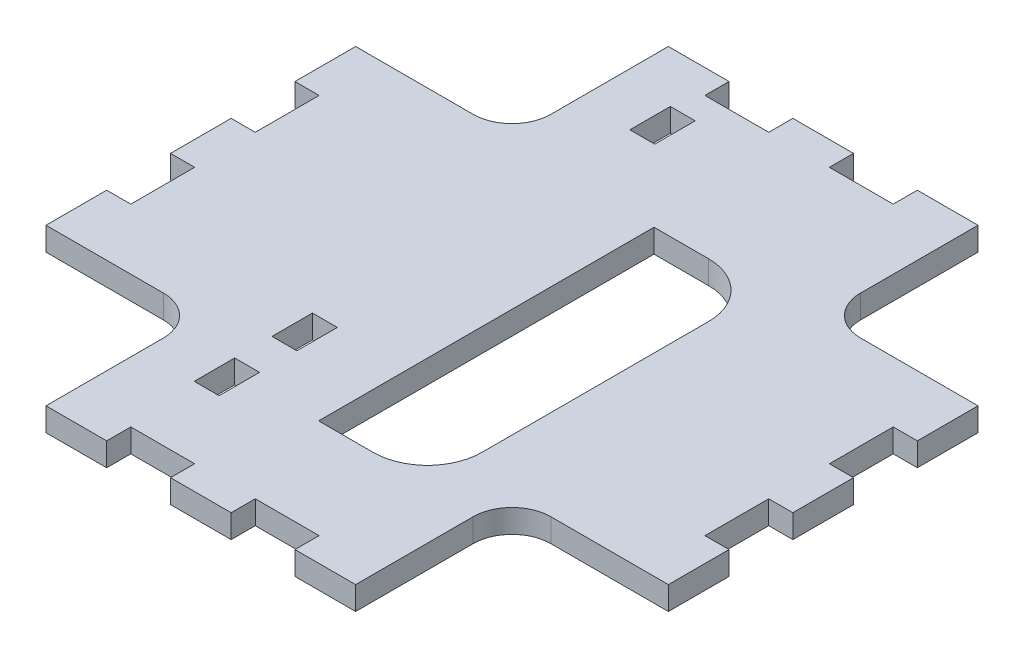
from build123d import *

# Parameters (mm, degrees)
SKETCH1_W           = 80
SKETCH1_H           = 80
SKETCH1_W_2         = 9
SKETCH1_H_2         = 43.113686922
BOSS_EXTRUDE1_DEPTH = 3
SKETCH3_W           = 8.2
SKETCH3_H           = 3.2
SKETCH3_W_2         = 3.2
SKETCH3_H_2         = 8.2
SKETCH3_W_3         = 20.2
SKETCH3_H_3         = 20.2
SKETCH3_H_4         = 5.2
CUT_EXTRUDE1_DEPTH  = 4
FILLET1_R           = 5
SKETCH4_W           = 5
SKETCH4_H           = 43.113686922
CUT_EXTRUDE2_DEPTH  = 4
FILLET2_R           = 7


with BuildPart() as part:
    # Sketch1 → Boss-Extrude1 (new body)
    with BuildSketch(Plane(origin=(0, 0, 0), x_dir=(1, 0, 0), z_dir=(0, 1, 0))):
        with Locations((40, 40)):
            Rectangle(SKETCH1_W, SKETCH1_H)
        with Locations((43.8, 37.4)):
            Rectangle(SKETCH1_W_2, SKETCH1_H_2, mode=Mode.SUBTRACT)
    extrude(amount=-BOSS_EXTRUDE1_DEPTH)

    # Sketch3 → Cut-Extrude1 (cut, through all)
    with BuildSketch(Plane(origin=(0, 0, 0), x_dir=(1, 0, 0), z_dir=(0, 1, 0))):
        with Locations((32, 1.5)):
            Rectangle(SKETCH3_W, SKETCH3_H)
        with Locations((78.5, 32)):
            Rectangle(SKETCH3_W_2, SKETCH3_H_2)
        with Locations((48, 1.5)):
            Rectangle(SKETCH3_W, SKETCH3_H)
        with Locations((1.5, 32)):
            Rectangle(SKETCH3_W_2, SKETCH3_H_2)
        with Locations((10, 10)):
            Rectangle(SKETCH3_W_3, SKETCH3_H_3)
        with Locations((70, 10)):
            Rectangle(SKETCH3_W_3, SKETCH3_H_3)
        with Locations((32, 78.5)):
            Rectangle(SKETCH3_W, SKETCH3_H)
        with Locations((1.5, 48)):
            Rectangle(SKETCH3_W_2, SKETCH3_H_2)
        with Locations((10, 70)):
            Rectangle(SKETCH3_W_3, SKETCH3_H_3)
        with Locations((78.5, 48)):
            Rectangle(SKETCH3_W_2, SKETCH3_H_2)
        with Locations((70, 70)):
            Rectangle(SKETCH3_W_3, SKETCH3_H_3)
        with Locations((48, 78.5)):
            Rectangle(SKETCH3_W, SKETCH3_H)
        with Locations((28.5, 14.85)):
            Rectangle(SKETCH3_W_2, SKETCH3_H_4)
        with Locations((28.5, 24.85)):
            Rectangle(SKETCH3_W_2, SKETCH3_H_4)
        with Locations((28.5, 70.85)):
            Rectangle(SKETCH3_W_2, SKETCH3_H_4)
    extrude(amount=-CUT_EXTRUDE1_DEPTH, mode=Mode.SUBTRACT)

    # Fillet1
    fillet1_edges = [part.edges().sort_by_distance(p)[0] for p in [
        (20.1, -1.5, -20.1),
        (59.9, -1.5, -20.1),
        (20.1, -1.5, -59.9),
        (59.9, -1.5, -59.9),
    ]]
    fillet(fillet1_edges, radius=FILLET1_R)

    # Sketch4 → Cut-Extrude2 (cut, through all)
    with BuildSketch(Plane(origin=(0, 0, 0), x_dir=(1, 0, 0), z_dir=(0, 1, 0))):
        with Locations((50.8, 37.4)):
            Rectangle(SKETCH4_W, SKETCH4_H)
    extrude(amount=-CUT_EXTRUDE2_DEPTH, mode=Mode.SUBTRACT)

    # Fillet2
    fillet2_edges = [part.edges().sort_by_distance(p)[0] for p in [
        (53.3, -1.5, -58.956843461),
        (53.3, -1.5, -15.843156539),
    ]]
    fillet(fillet2_edges, radius=FILLET2_R)


solid = part.part
